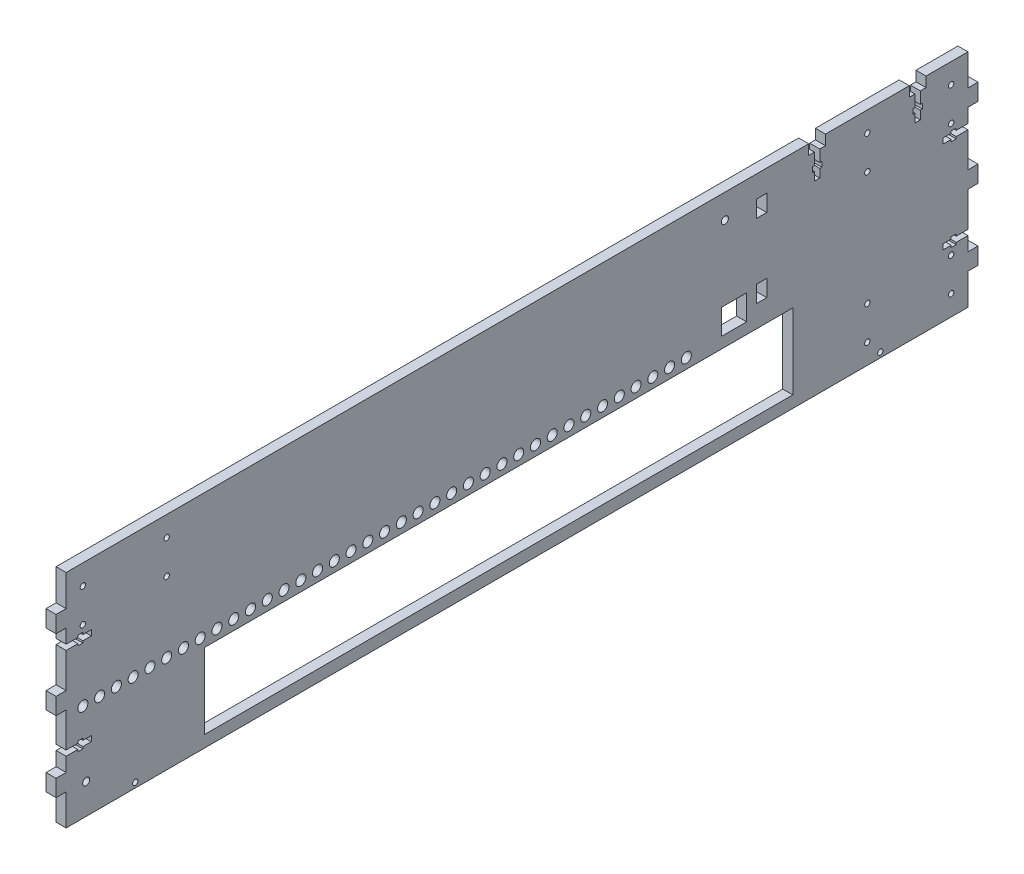
from build123d import *

# Parameters (mm, degrees)
SKETCH1_W           = 538
SKETCH1_H           = 132
BOSS_EXTRUDE1_DEPTH = 6
SKETCH4_W           = 6
SKETCH4_H           = 10
BOSS_EXTRUDE2_DEPTH = 6
CUT_EXTRUDE3_REACH  = 8
SKETCH6_W           = 6
SKETCH6_H           = 10
BOSS_EXTRUDE3_DEPTH = 6
CUT_EXTRUDE4_REACH  = 8
CUT_EXTRUDE5_REACH  = 8
SKETCH8_W           = 351
SKETCH8_H           = 44.95
CUT_EXTRUDE8_REACH  = 8
SKETCH11_W          = 6
SKETCH11_H          = 10
CUT_EXTRUDE9_REACH  = 8
SKETCH12_R          = 2.1
SKETCH13_W          = 6
SKETCH13_H          = 10
CUT_EXTRUDE10_DEPTH = 6
SKETCH14_R          = 3
CUT_EXTRUDE11_DEPTH = 6
CUT_EXTRUDE12_REACH = 8
SKETCH17_R          = 2.1
CUT_EXTRUDE14_DEPTH = 7
SKETCH18_R          = 1.6
CUT_EXTRUDE15_DEPTH = 7
SKETCH19_R          = 1.6
CUT_EXTRUDE16_DEPTH = 7
SKETCH20_W          = 15
SKETCH20_H          = 15
CUT_EXTRUDE17_DEPTH = 7


with BuildPart() as part:
    # Sketch1 → Boss-Extrude1 (new body)
    with BuildSketch(Plane(origin=(0, 0, 0), x_dir=(0, 0, -1), z_dir=(1, 0, 0))):
        Rectangle(SKETCH1_W, SKETCH1_H)
    extrude(amount=BOSS_EXTRUDE1_DEPTH)

    # Sketch4 → Boss-Extrude2 (add)
    with BuildSketch(Plane.XY.offset(269)):
        with Locations((3, 42.332128782)):
            Rectangle(SKETCH4_W, SKETCH4_H)
        with Locations((3, 0)):
            Rectangle(SKETCH4_W, SKETCH4_H)
        with Locations((3, -42.332128782)):
            Rectangle(SKETCH4_W, SKETCH4_H)
    extrude(amount=BOSS_EXTRUDE2_DEPTH)

    # Sketch5 → Cut-Extrude3 (cut, up to next)
    with BuildSketch(Plane.ZY, mode=Mode.PRIVATE) as cut_extrude3_sk1:
        Polygon((269, -25.732128782), (262, -25.732128782), (262, -24.532128782), (259, -24.532128782), (259, -25.732128782), (254, -25.732128782), (254, -28.932128782), (259, -28.932128782), (259, -30.132128782), (262, -30.132128782), (262, -28.932128782), (269, -28.932128782), align=None)
    cut_extrude3_tool1 = extrude(cut_extrude3_sk1.sketch, amount=-CUT_EXTRUDE3_REACH, mode=Mode.PRIVATE) & part.part
    add(cut_extrude3_tool1.solids().sort_by_distance((0, -27.332129, 261.369565))[0], mode=Mode.SUBTRACT)
    # Sketch5 → Cut-Extrude3 (cut, up to next)
    with BuildSketch(Plane.ZY, mode=Mode.PRIVATE) as cut_extrude3_sk2:
        Polygon((269, 28.932128782), (262, 28.932128782), (262, 30.132128782), (259, 30.132128782), (259, 28.932128782), (254, 28.932128782), (254, 25.732128782), (259, 25.732128782), (259, 24.532128782), (262, 24.532128782), (262, 25.732128782), (269, 25.732128782), align=None)
    cut_extrude3_tool2 = extrude(cut_extrude3_sk2.sketch, amount=-CUT_EXTRUDE3_REACH, mode=Mode.PRIVATE) & part.part
    add(cut_extrude3_tool2.solids().sort_by_distance((0, 27.332129, 261.369565))[0], mode=Mode.SUBTRACT)

    # Sketch6 → Boss-Extrude3 (add)
    with BuildSketch(Plane(origin=(0, 0, -269), x_dir=(-1, 0, 0), z_dir=(0, 0, -1))):
        with Locations((-3, 42.332128782)):
            Rectangle(SKETCH6_W, SKETCH6_H)
        with Locations((-3, 0)):
            Rectangle(SKETCH6_W, SKETCH6_H)
        with Locations((-3, -42.332128782)):
            Rectangle(SKETCH6_W, SKETCH6_H)
    extrude(amount=BOSS_EXTRUDE3_DEPTH)

    # Sketch7 → Cut-Extrude4 (cut, up to next)
    with BuildSketch(Plane.ZY, mode=Mode.PRIVATE) as cut_extrude4_sk1:
        Polygon((-254, -28.932128782), (-254, -25.732128782), (-259, -25.732128782), (-259, -24.532128782), (-262, -24.532128782), (-262, -25.732128782), (-269, -25.732128782), (-269, -28.932128782), (-262, -28.932128782), (-262, -30.132128782), (-259, -30.132128782), (-259, -28.932128782), align=None)
    cut_extrude4_tool1 = extrude(cut_extrude4_sk1.sketch, amount=-CUT_EXTRUDE4_REACH, mode=Mode.PRIVATE) & part.part
    add(cut_extrude4_tool1.solids().sort_by_distance((0, -27.332129, -261.369565))[0], mode=Mode.SUBTRACT)
    # Sketch7 → Cut-Extrude4 (cut, up to next)
    with BuildSketch(Plane.ZY, mode=Mode.PRIVATE) as cut_extrude4_sk2:
        Polygon((-262, 28.932128782), (-269, 28.932128782), (-269, 25.732128782), (-262, 25.732128782), (-262, 24.532128782), (-259, 24.532128782), (-259, 25.732128782), (-254, 25.732128782), (-254, 28.932128782), (-259, 28.932128782), (-259, 30.132128782), (-262, 30.132128782), align=None)
    cut_extrude4_tool2 = extrude(cut_extrude4_sk2.sketch, amount=-CUT_EXTRUDE4_REACH, mode=Mode.PRIVATE) & part.part
    add(cut_extrude4_tool2.solids().sort_by_distance((0, 27.332129, -261.369565))[0], mode=Mode.SUBTRACT)

    # Sketch8 → Cut-Extrude5 (cut, up to next)
    with BuildSketch(Plane.ZY, mode=Mode.PRIVATE) as cut_extrude5_sk1:
        with Locations((11, -36.525)):
            Rectangle(SKETCH8_W, SKETCH8_H)
    cut_extrude5_tool1 = extrude(cut_extrude5_sk1.sketch, amount=-CUT_EXTRUDE5_REACH, mode=Mode.PRIVATE) & part.part
    add(cut_extrude5_tool1.solids().sort_by_distance((0, -36.525, 11))[0], mode=Mode.SUBTRACT)

    # Sketch11 → Cut-Extrude8 (cut, up to next)
    with BuildSketch(Plane(origin=(6, 0, 0), x_dir=(0, 0, -1), z_dir=(1, 0, 0)), mode=Mode.PRIVATE) as cut_extrude8_sk1:
        with Locations((146, 48)):
            Rectangle(SKETCH11_W, SKETCH11_H)
    cut_extrude8_tool1 = extrude(cut_extrude8_sk1.sketch, amount=-CUT_EXTRUDE8_REACH, mode=Mode.PRIVATE) & part.part
    add(cut_extrude8_tool1.solids().sort_by_distance((6, 48, -146))[0], mode=Mode.SUBTRACT)
    # Sketch11 → Cut-Extrude8 (cut, up to next)
    with BuildSketch(Plane(origin=(6, 0, 0), x_dir=(0, 0, -1), z_dir=(1, 0, 0)), mode=Mode.PRIVATE) as cut_extrude8_sk2:
        with Locations((146, 4)):
            Rectangle(SKETCH11_W, SKETCH11_H)
    cut_extrude8_tool2 = extrude(cut_extrude8_sk2.sketch, amount=-CUT_EXTRUDE8_REACH, mode=Mode.PRIVATE) & part.part
    add(cut_extrude8_tool2.solids().sort_by_distance((6, 4, -146))[0], mode=Mode.SUBTRACT)

    # Sketch12 → Cut-Extrude9 (cut, up to next)
    with BuildSketch(Plane.ZY, mode=Mode.PRIVATE) as cut_extrude9_sk1:
        with Locations((-124, 51.5)):
            Circle(SKETCH12_R)
    cut_extrude9_tool1 = extrude(cut_extrude9_sk1.sketch, amount=-CUT_EXTRUDE9_REACH, mode=Mode.PRIVATE) & part.part
    add(cut_extrude9_tool1.solids().sort_by_distance((0, 51.5, -124))[0], mode=Mode.SUBTRACT)

    # Sketch13 → Cut-Extrude10 (cut)
    with BuildSketch(Plane(origin=(0, 66, 0), x_dir=(1, 0, 0), z_dir=(0, 1, 0))):
        with Locations((3, 239)):
            Rectangle(SKETCH13_W, SKETCH13_H)
        with Locations((3, 179)):
            Rectangle(SKETCH13_W, SKETCH13_H)
    extrude(amount=-CUT_EXTRUDE10_DEPTH, mode=Mode.SUBTRACT)

    # Sketch14 → Cut-Extrude11 (cut)
    with BuildSketch(Plane.ZY):
        with Locations((259, -8)):
            Circle(SKETCH14_R)
        with Locations((249, -8)):
            Circle(SKETCH14_R)
        with Locations((239, -8)):
            Circle(SKETCH14_R)
        with Locations((229, -8)):
            Circle(SKETCH14_R)
        with Locations((219, -8)):
            Circle(SKETCH14_R)
        with Locations((209, -8)):
            Circle(SKETCH14_R)
        with Locations((199, -8)):
            Circle(SKETCH14_R)
        with Locations((189, -8)):
            Circle(SKETCH14_R)
        with Locations((179, -8)):
            Circle(SKETCH14_R)
        with Locations((169, -8)):
            Circle(SKETCH14_R)
        with Locations((159, -8)):
            Circle(SKETCH14_R)
        with Locations((149, -8)):
            Circle(SKETCH14_R)
        with Locations((139, -8)):
            Circle(SKETCH14_R)
        with Locations((129, -8)):
            Circle(SKETCH14_R)
        with Locations((119, -8)):
            Circle(SKETCH14_R)
        with Locations((109, -8)):
            Circle(SKETCH14_R)
        with Locations((99, -8)):
            Circle(SKETCH14_R)
        with Locations((89, -8)):
            Circle(SKETCH14_R)
        with Locations((79, -8)):
            Circle(SKETCH14_R)
        with Locations((69, -8)):
            Circle(SKETCH14_R)
        with Locations((59, -8)):
            Circle(SKETCH14_R)
        with Locations((49, -8)):
            Circle(SKETCH14_R)
        with Locations((39, -8)):
            Circle(SKETCH14_R)
        with Locations((29, -8)):
            Circle(SKETCH14_R)
        with Locations((19, -8)):
            Circle(SKETCH14_R)
        with Locations((9, -8)):
            Circle(SKETCH14_R)
        with Locations((-1, -8)):
            Circle(SKETCH14_R)
        with Locations((-11, -8)):
            Circle(SKETCH14_R)
        with Locations((-21, -8)):
            Circle(SKETCH14_R)
        with Locations((-31, -8)):
            Circle(SKETCH14_R)
        with Locations((-41, -8)):
            Circle(SKETCH14_R)
        with Locations((-51, -8)):
            Circle(SKETCH14_R)
        with Locations((-61, -8)):
            Circle(SKETCH14_R)
        with Locations((-71, -8)):
            Circle(SKETCH14_R)
        with Locations((-81, -8)):
            Circle(SKETCH14_R)
        with Locations((-91, -8)):
            Circle(SKETCH14_R)
        with Locations((-101, -8)):
            Circle(SKETCH14_R)
    extrude(amount=-CUT_EXTRUDE11_DEPTH, mode=Mode.SUBTRACT)

    # Sketch15 → Cut-Extrude12 (cut, up to next)
    with BuildSketch(Plane(origin=(6, 0, 0), x_dir=(0, 0, -1), z_dir=(1, 0, 0)), mode=Mode.PRIVATE) as cut_extrude12_sk1:
        Polygon((177.4, 60), (177.4, 53), (176.2, 53), (176.2, 50), (177.4, 50), (177.4, 45), (180.6, 45), (180.6, 50), (181.8, 50), (181.8, 53), (180.6, 53), (180.6, 60), align=None)
    cut_extrude12_tool1 = extrude(cut_extrude12_sk1.sketch, amount=-CUT_EXTRUDE12_REACH, mode=Mode.PRIVATE) & part.part
    add(cut_extrude12_tool1.solids().sort_by_distance((6, 52.369565, -179))[0], mode=Mode.SUBTRACT)
    # Sketch15 → Cut-Extrude12 (cut, up to next)
    with BuildSketch(Plane(origin=(6, 0, 0), x_dir=(0, 0, -1), z_dir=(1, 0, 0)), mode=Mode.PRIVATE) as cut_extrude12_sk2:
        Polygon((237.4, 50), (237.4, 45), (240.6, 45), (240.6, 50), (241.8, 50), (241.8, 53), (240.6, 53), (240.6, 60), (237.4, 60), (237.4, 53), (236.2, 53), (236.2, 50), align=None)
    cut_extrude12_tool2 = extrude(cut_extrude12_sk2.sketch, amount=-CUT_EXTRUDE12_REACH, mode=Mode.PRIVATE) & part.part
    add(cut_extrude12_tool2.solids().sort_by_distance((6, 52.369565, -239))[0], mode=Mode.SUBTRACT)

    # Sketch17 → Cut-Extrude14 (cut, through all)
    with BuildSketch(Plane(origin=(6, 0, 0), x_dir=(0, 0, -1), z_dir=(1, 0, 0))):
        with Locations((-257, -48)):
            Circle(SKETCH17_R)
    extrude(amount=-CUT_EXTRUDE14_DEPTH, mode=Mode.SUBTRACT)

    # Sketch18 → Cut-Extrude15 (cut, through all)
    with BuildSketch(Plane(origin=(6, 0, 0), x_dir=(0, 0, -1), z_dir=(1, 0, 0))):
        with Locations((-227.75, -63)):
            Circle(SKETCH18_R)
        with Locations((216.75, -63)):
            Circle(SKETCH18_R)
    extrude(amount=-CUT_EXTRUDE15_DEPTH, mode=Mode.SUBTRACT)

    # Sketch19 → Cut-Extrude16 (cut, through all)
    with BuildSketch(Plane(origin=(6, 0, 0), x_dir=(0, 0, -1), z_dir=(1, 0, 0))):
        with Locations((259, -34)):
            Circle(SKETCH19_R)
        with Locations((259, 54)):
            Circle(SKETCH19_R)
        with Locations((259, -54)):
            Circle(SKETCH19_R)
        with Locations((209, -54)):
            Circle(SKETCH19_R)
        with Locations((209, -34)):
            Circle(SKETCH19_R)
        with Locations((209, 34)):
            Circle(SKETCH19_R)
        with Locations((209, 54)):
            Circle(SKETCH19_R)
        with Locations((259, 34)):
            Circle(SKETCH19_R)
        with Locations((-209, 34)):
            Circle(SKETCH19_R)
        with Locations((-259, 34)):
            Circle(SKETCH19_R)
        with Locations((-209, 54)):
            Circle(SKETCH19_R)
        with Locations((-259, 54)):
            Circle(SKETCH19_R)
    extrude(amount=-CUT_EXTRUDE16_DEPTH, mode=Mode.SUBTRACT)

    # Sketch20 → Cut-Extrude17 (cut, through all)
    with BuildSketch(Plane(origin=(6, 0, 0), x_dir=(0, 0, -1), z_dir=(1, 0, 0))):
        with Locations((129.5, 0)):
            Rectangle(SKETCH20_W, SKETCH20_H)
    extrude(amount=-CUT_EXTRUDE17_DEPTH, mode=Mode.SUBTRACT)


solid = part.part
